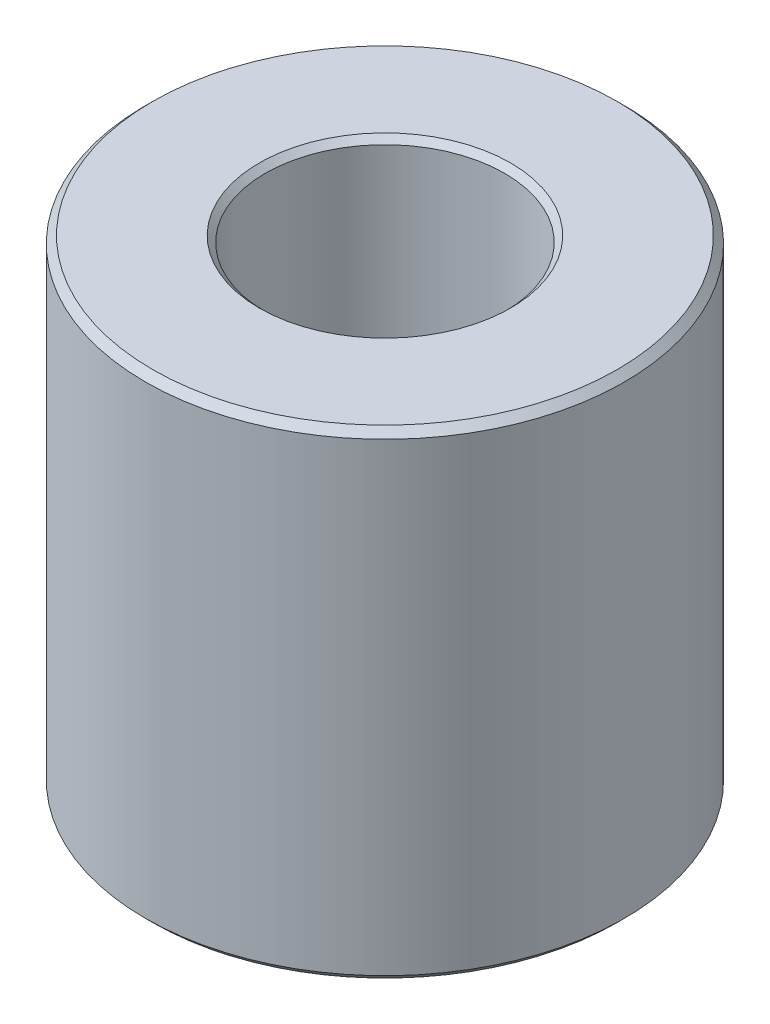
from build123d import *

# Parameters (mm, degrees)
SKETCH1_R                  = 25.4
EXTRUDE1_DEPTH             = 50.8
F_1_2_0_5_DIAMETER_HOLE1_D = 12.7254
CHAMFER1_SIZE              = 0.762
F_1_1_DIAMETER_HOLE1_D     = 25.4
F_1_1_DIAMETER_HOLE1_DEPTH = 42.418
CHAMFER2_SIZE              = 0.254
CHAMFER3_SIZE              = 0.635


with BuildPart() as part:
    # Sketch1 → Extrude1 (new body)
    with BuildSketch(Plane(origin=(0, 0, 0), x_dir=(1, 0, 0), z_dir=(0, 1, 0))):
        with Locations(Location((0, 0, 0), (0, 0, 270))):  # turned: the seam where the file's is
            Circle(SKETCH1_R)
    extrude(amount=EXTRUDE1_DEPTH)

    # 1/2 (0.5) Diameter Hole1 (through all)
    with Locations(Plane(origin=(0, 50.8, 0), x_dir=(-1, 0, 0), z_dir=(0, 1, 0))):
        with Locations((0, 0)):
            Hole(F_1_2_0_5_DIAMETER_HOLE1_D / 2)

    # Chamfer1
    chamfer1_edges = [part.edges().sort_by_distance(p)[0] for p in [
        (0, 0, -25.4),
        (0, 50.8, -25.4),
        (-6.3627, 0, 0),
    ]]
    chamfer(chamfer1_edges, length=CHAMFER1_SIZE)

    # 1 (1) Diameter Hole1
    with Locations(Plane(origin=(0, 50.8, 0), x_dir=(-1, 0, 0), z_dir=(0, 1, 0))):
        with Locations((0, 0)):
            Hole(F_1_1_DIAMETER_HOLE1_D / 2, depth=F_1_1_DIAMETER_HOLE1_DEPTH)

    # Chamfer2
    chamfer2_edges = [part.edges().sort_by_distance(p)[0] for p in [
        (-12.7, 8.382, 0),
    ]]
    chamfer(chamfer2_edges, length=CHAMFER2_SIZE)

    # Chamfer3
    chamfer3_edges = [part.edges().sort_by_distance(p)[0] for p in [
        (-12.7, 50.8, 0),
    ]]
    chamfer(chamfer3_edges, length=CHAMFER3_SIZE)


solid = part.part
